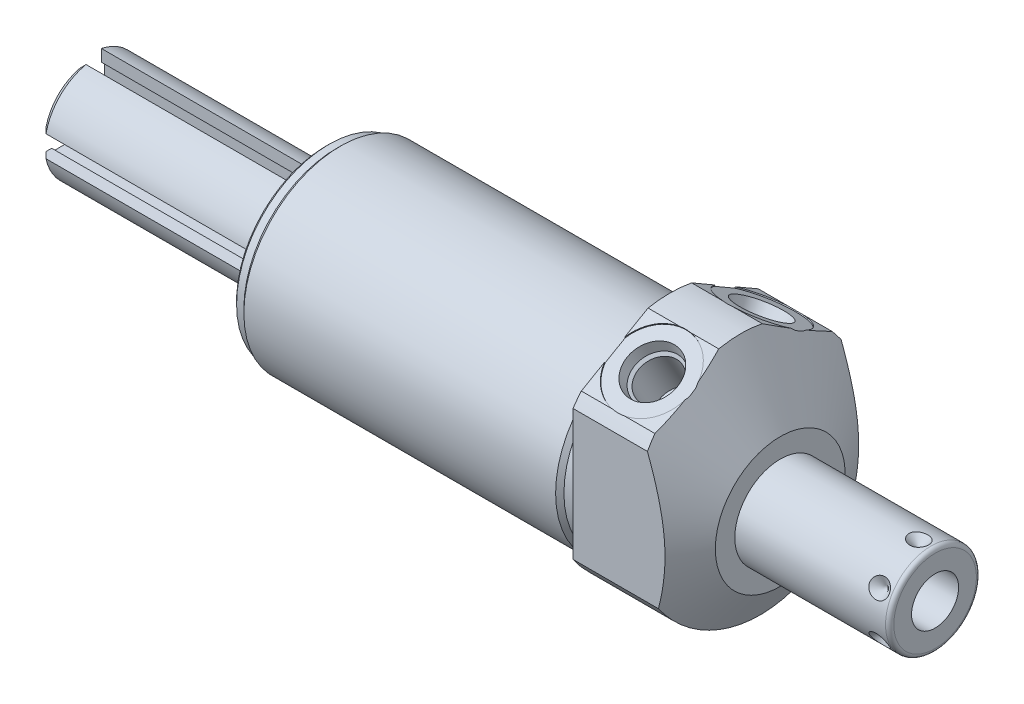
from build123d import *

# Parameters (mm, degrees)
SKETCH1_R           = 28.575
EXTRUDE1_DEPTH      = 27.0002
EXTRUDE1_DEPTH_BACK = 84.1248
CUT_EXTRUDE1_REACH  = 86.125
SKETCH2_R           = 28.575
SKETCH2_R_2         = 23.622
CUT_EXTRUDE3_START  = -27.0002
CUT_EXTRUDE3_DEPTH  = 27.0002
SKETCH18_R          = 9.525
CUT_EXTRUDE4_DEPTH  = 0.254
SKETCH19_R          = 9.525
CUT_EXTRUDE5_DEPTH  = 0.254
CHAMFER1_SIZE       = 0.762
CIRPATTERN1_COUNT   = 6
SKETCH20_R          = 21.0312
CUT_EXTRUDE9_DEPTH  = 0.127
SKETCH22_R          = 21.0312
SKETCH22_R_2        = 20.7772
CUT_EXTRUDE10_DEPTH = 1.524
SKETCH23_R          = 12.7
EXTRUDE2_DEPTH      = 57.6834
CUT_EXTRUDE11_DEPTH = 52.9082
SKETCH25_R          = 3.429
CUT_EXTRUDE12_DEPTH = 18.4752001
CIRPATTERN2_COUNT   = 4
CHAMFER2_SIZE       = 1.524


with BuildPart() as part:
    # Sketch1 → Extrude1 (new body, two sides)
    with BuildSketch(Plane(origin=(0, 0, 0), x_dir=(0, 0, -1), z_dir=(1, 0, 0))) as extrude1_sk:
        Circle(SKETCH1_R)
    extrude(amount=EXTRUDE1_DEPTH)
    extrude(extrude1_sk.sketch, amount=-EXTRUDE1_DEPTH_BACK)

    # Sketch2 → Cut-Extrude1 (cut, up to next)
    with BuildSketch(Plane(origin=(0, 0, 0), x_dir=(0, 0, -1), z_dir=(1, 0, 0)), mode=Mode.PRIVATE) as cut_extrude1_sk1:
        Circle(SKETCH2_R)
        with Locations((0, -4.191)):
            Circle(SKETCH2_R_2, mode=Mode.SUBTRACT)
    cut_extrude1_tool1 = extrude(cut_extrude1_sk1.sketch, amount=-CUT_EXTRUDE1_REACH, mode=Mode.PRIVATE) & part.part
    add(cut_extrude1_tool1.solids().sort_by_distance((0, 0, 27.766777))[0], mode=Mode.SUBTRACT)

    # Sketch4 → Cut-Extrude3 (cut)
    with BuildSketch(Plane.ZY.offset(CUT_EXTRUDE3_START)):
        with BuildLine():
            Line((23.6855, -25.666178421), (23.6855, 17.476089577))
            Line((23.6855, 17.476089577), (0, 31.150919378))
            Line((0, 31.150919378), (-23.6855, 17.476089577))
            Line((-23.6855, 17.476089577), (-23.6855, -25.666178421))
            ThreePointArc((-23.6855, -25.666178421), (0, 34.925), (23.6855, -25.666178421))
        make_face()
    extrude(amount=CUT_EXTRUDE3_DEPTH, mode=Mode.SUBTRACT)

    # Sketch6 → Cut-Revolve2 (revolve, cut)
    with BuildSketch(Plane.XY, mode=Mode.PRIVATE) as cut_revolve2_sk:
        Polygon((0.750392661, 57.15), (27.0002, 11.684), (27.0002, 57.15), align=None)
    revolve(cut_revolve2_sk.sketch.rotate(Axis((-0.562097706, -4.191, 0), (1, 0, 0)), 270), axis=Axis((-0.562097706, -4.191, 0), (1, 0, 0)), mode=Mode.SUBTRACT)  # turned: the seam where the file's is

    # S2D0002 → Cut-Revolve3 (revolve, cut)
    with BuildSketch(Plane(origin=(9.0932, 23.136869081, 13.372742289), x_dir=(0, 0.5, -0.866025404), z_dir=(1, 0, 0))):
        Polygon((0, 0), (6.1849, 0), (5.642306865, -2.5527), (4.9784, -3.216606865), (4.9784, -13.462), (0, -13.462), align=None)
    revolve(axis=Axis((9.0932, 10.895513396, 6.305192289), (0, 0.866025404, 0.5)), mode=Mode.SUBTRACT)

    # Sketch8 → Cut-Revolve4 (revolve, cut)
    with BuildSketch(Plane(origin=(9.0932, 23.136869081, -13.372742289), x_dir=(0, -0.5, -0.866025404), z_dir=(1, 0, 0))):
        Polygon((0, 0), (6.1849, 0), (5.642306865, -2.5527), (4.9784, -3.216606865), (4.9784, -13.462), (0, -13.462), align=None)
    revolve(axis=Axis((9.0932, 10.895513396, -6.305192289), (0, 0.866025404, -0.5)), mode=Mode.SUBTRACT)

    # Sketch18 → Cut-Extrude4 (cut)
    with BuildSketch(Plane(origin=(0, 23.363189534, 13.488743766), x_dir=(1, 0, 0), z_dir=(0, 0.866025404, 0.5))):
        with Locations((9.0932, -0.0127)):
            Circle(SKETCH18_R)
    extrude(amount=-CUT_EXTRUDE4_DEPTH, mode=Mode.SUBTRACT)

    # Sketch19 → Cut-Extrude5 (cut)
    with BuildSketch(Plane(origin=(0, 23.363189534, -13.488743766), x_dir=(1, 0, 0), z_dir=(0, 0.866025404, -0.5))):
        with Locations((9.0932, 0.0127)):
            Circle(SKETCH19_R)
    extrude(amount=-CUT_EXTRUDE5_DEPTH, mode=Mode.SUBTRACT)

    # Sketch10 → Cut-Revolve6 (revolve, cut)
    with BuildSketch(Plane.XY, mode=Mode.PRIVATE) as cut_revolve6_sk:
        Polygon((0, 19.431), (0, 18.415), (-3.302, 18.415), (-4.318, 19.431), align=None)
    revolve(cut_revolve6_sk.sketch.rotate(Axis((-4.5339, -4.191, 0), (1, 0, 0)), 90), axis=Axis((-4.5339, -4.191, 0), (1, 0, 0)), mode=Mode.SUBTRACT)  # turned: the seam where the file's is

    # Sketch12 → Cut-Revolve8 (revolve, cut)
    with BuildSketch(Plane.XY, mode=Mode.PRIVATE) as cut_revolve8_sk:
        Polygon((-84.1248, 19.431), (-84.1248, 18.415), (-81.5848, 18.415), (-80.5688, 19.431), align=None)
    revolve(cut_revolve8_sk.sketch.rotate(Axis((-84.3026, -4.191, 0), (1, 0, 0)), 90), axis=Axis((-84.3026, -4.191, 0), (1, 0, 0)), mode=Mode.SUBTRACT)  # turned: the seam where the file's is

    # Chamfer1
    chamfer1_edges = [part.edges().sort_by_distance(p)[0] for p in [
        (-84.1248, -4.191, -22.606),
    ]]
    chamfer(chamfer1_edges, length=CHAMFER1_SIZE)

    # Sketch13 → Revolve1 (revolve)
    with BuildSketch(Plane(origin=(0, 0, 0), x_dir=(0, -1, 0), z_dir=(0, 0, 1)), mode=Mode.PRIVATE) as revolve1_sk:
        with BuildLine():
            Line((4.191, 27.0002), (4.191, 64.8716))
            Line((4.191, 64.8716), (14.2875, 64.8716))
            ThreePointArc((14.2875, 64.8716), (15.00592049, 64.57402049), (15.3035, 63.8556))
            Line((15.3035, 63.8556), (15.3035, 27.0002))
            Line((15.3035, 27.0002), (4.191, 27.0002))
        make_face()
    revolve(revolve1_sk.sketch.rotate(Axis((25.10663, -4.191, 0), (1, 0, 0)), 270), axis=Axis((25.10663, -4.191, 0), (1, 0, 0)))  # turned: the seam where the file's is

    # S2D0001 → Cut-Revolve9 (revolve, cut)
    with BuildSketch(Plane(origin=(64.8716, -9.9441, 0), x_dir=(0, -1, 0), z_dir=(0, 0, 1)), mode=Mode.PRIVATE) as cut_revolve9_sk:
        Polygon((0, 0), (0, -17.018), (-5.7531, -20.474811227), (-5.7531, 0), align=None)
    revolve(cut_revolve9_sk.sketch.rotate(Axis((43.373048211, -4.191, 0), (1, 0, 0)), 270), axis=Axis((43.373048211, -4.191, 0), (1, 0, 0)), mode=Mode.SUBTRACT)  # turned: the seam where the file's is

    # Sketch16 → Cut-Revolve10 (revolve, cut)
    with BuildSketch(Plane(origin=(60.9092, 6.9215, 0), x_dir=(-1, 0, 0), z_dir=(0, 0, -1)), mode=Mode.PRIVATE) as cut_revolve10_sk:
        Polygon((0, 0), (2.413, 0), (0, -2.413), align=None)
    cut_revolve10 = revolve(cut_revolve10_sk.sketch.rotate(Axis((60.9092, 2.435048935, 0), (0, 1, 0)), 90), axis=Axis((60.9092, 2.435048935, 0), (0, 1, 0)), mode=Mode.SUBTRACT)  # turned: the seam where the file's is

    # CirPattern1: Cut-Revolve10 ×6 about axis
    cirpattern1_axis = Axis((25.10663, -4.191, 0), (-1, 0, 0))
    for i in range(1, CIRPATTERN1_COUNT):
        add(cut_revolve10.rotate(cirpattern1_axis, i * 360 / CIRPATTERN1_COUNT), mode=Mode.SUBTRACT)

    # Sketch20 → Cut-Extrude9 (cut)
    with BuildSketch(Plane.ZY.offset(84.1248)):
        with Locations((0, -4.191)):
            Circle(SKETCH20_R)
    extrude(amount=-CUT_EXTRUDE9_DEPTH, mode=Mode.SUBTRACT)

    # Sketch22 → Cut-Extrude10 (cut)
    with BuildSketch(Plane.ZY.offset(84.1248)):
        with Locations((0, -4.191)):
            Circle(SKETCH22_R)
        with Locations((0, -4.191)):
            Circle(SKETCH22_R_2, mode=Mode.SUBTRACT)
    extrude(amount=-CUT_EXTRUDE10_DEPTH, mode=Mode.SUBTRACT)

    # Sketch23 → Extrude2 (add)
    with BuildSketch(Plane.ZY.offset(83.9978)):
        with Locations((0, -4.191)):
            Circle(SKETCH23_R)
    extrude(amount=EXTRUDE2_DEPTH)

    # Sketch24 → Cut-Extrude11 (cut)
    with BuildSketch(Plane.ZY.offset(141.6812)):
        with BuildLine():
            Line((12.422236089, -1.5494), (9.5123, -1.5494))
            Line((9.5123, -1.5494), (9.5123, -0.762))
            Line((9.5123, -0.762), (6.2103, -0.762))
            Line((6.2103, -0.762), (6.2103, -7.62))
            Line((6.2103, -7.62), (9.5123, -7.62))
            Line((9.5123, -7.62), (9.5123, -6.8326))
            Line((9.5123, -6.8326), (12.422236089, -6.8326))
            ThreePointArc((12.422236089, -6.8326), (12.7, -4.191), (12.422236089, -1.5494))
        make_face()
    cut_extrude11 = extrude(amount=-CUT_EXTRUDE11_DEPTH, mode=Mode.SUBTRACT)

    # Sketch25 → Cut-Extrude12 (cut, through all)
    with BuildSketch(Plane.XY.offset(6.2103)):
        with Locations((-88.773, -4.191)):
            Circle(SKETCH25_R)
    cut_extrude12 = extrude(amount=CUT_EXTRUDE12_DEPTH, mode=Mode.SUBTRACT)

    # CirPattern2: Cut-Extrude11, Cut-Extrude12 ×4 about axis
    cirpattern2_axis = Axis((0, -4.191, 0), (1, 0, 0))
    add([cut_extrude11.rotate(cirpattern2_axis, i * 360 / CIRPATTERN2_COUNT) for i in range(1, CIRPATTERN2_COUNT)], mode=Mode.SUBTRACT)
    add([cut_extrude12.rotate(cirpattern2_axis, i * 360 / CIRPATTERN2_COUNT) for i in range(1, CIRPATTERN2_COUNT)], mode=Mode.SUBTRACT)

    # Chamfer2
    chamfer2_edges = [part.edges().sort_by_distance(p)[0] for p in [
        (-141.6812, 4.789256121, 8.980256121),
        (-141.6812, -13.171256121, 8.980256121),
    ]]
    chamfer(chamfer2_edges, length=CHAMFER2_SIZE)


solid = part.part
